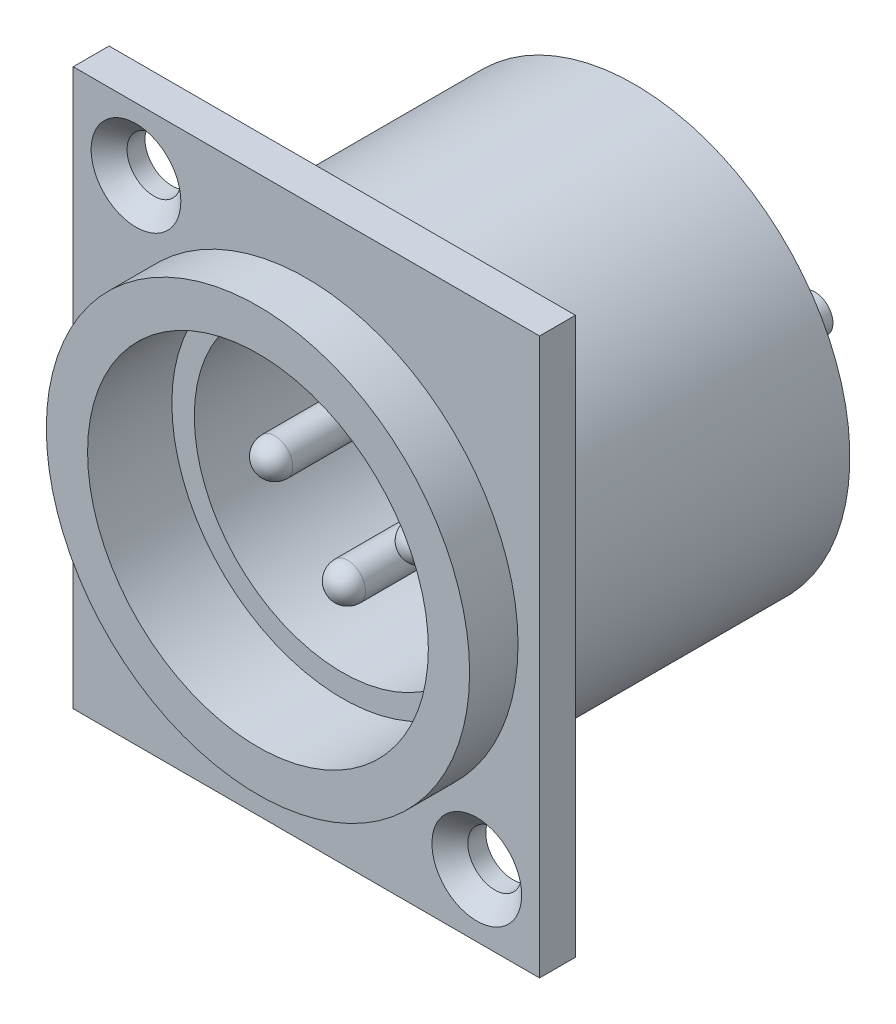
from build123d import *

# Parameters (mm, degrees)
ESQUISSE1_W             = 26
ESQUISSE1_H             = 31
ESQUISSE1_R             = 9.5
ESQUISSE1_R_2           = 1.5
BOSS_EXTRU_1_DEPTH      = 2
ESQUISSE2_R             = 11.8
ESQUISSE2_R_2           = 9.5
BOSS_EXTRU_2_DEPTH      = 2.7
CHANFREIN1_SIZE         = 1
ESQUISSE3_R             = 12
ESQUISSE3_R_2           = 8.25
BOSS_EXTRU_3_DEPTH      = 14.3
ESQUISSE4_R             = 12
BOSS_EXTRU_4_DEPTH      = 2
ESQUISSE5_R             = 1
BOSS_EXTRU_5_DEPTH      = 15
BOSS_EXTRU_5_DEPTH_BACK = 8
CONG_1_R                = 1


with BuildPart() as part:
    # Esquisse1 → Boss.-Extru.1 (new body)
    with BuildSketch(Plane.XY):
        with Locations((3.183515483, -7.666666667)):
            Rectangle(ESQUISSE1_W, ESQUISSE1_H)
        with Locations((3.183515483, -7.666666667)):
            Circle(ESQUISSE1_R, mode=Mode.SUBTRACT)
        with Locations((-6.316484517, 4.333333333)):
            Circle(ESQUISSE1_R_2, mode=Mode.SUBTRACT)
        with Locations((12.683515483, -19.666666667)):
            Circle(ESQUISSE1_R_2, mode=Mode.SUBTRACT)
    extrude(amount=BOSS_EXTRU_1_DEPTH)

    # Esquisse2 → Boss.-Extru.2 (add)
    with BuildSketch(Plane.XY.offset(2)):
        with Locations((3.183515483, -7.666666667)):
            Circle(ESQUISSE2_R)
        with Locations((3.183515483, -7.666666667)):
            Circle(ESQUISSE2_R_2, mode=Mode.SUBTRACT)
    extrude(amount=BOSS_EXTRU_2_DEPTH)

    # Chanfrein1
    chanfrein1_edges = [part.edges().sort_by_distance(p)[0] for p in [
        (-7.816484517, 4.333333333, 2),
        (11.183515483, -19.666666667, 2),
    ]]
    chamfer(chanfrein1_edges, length=CHANFREIN1_SIZE)

    # Esquisse3 → Boss.-Extru.3 (add)
    with BuildSketch(Plane(origin=(0, 0, 0), x_dir=(-1, 0, 0), z_dir=(0, 0, -1))):
        with Locations((-3.183515483, -7.666666667)):
            Circle(ESQUISSE3_R)
        with Locations((-3.183515483, -7.666666667)):
            Circle(ESQUISSE3_R_2, mode=Mode.SUBTRACT)
    extrude(amount=BOSS_EXTRU_3_DEPTH)

    # Esquisse4 → Boss.-Extru.4 (add)
    with BuildSketch(Plane(origin=(0, 0, -14.3), x_dir=(-1, 0, 0), z_dir=(0, 0, -1))):
        with Locations((-3.183515483, -7.666666667)):
            Circle(ESQUISSE4_R)
    extrude(amount=BOSS_EXTRU_4_DEPTH)

    # Esquisse5 → Boss.-Extru.5 (add, two sides)
    with BuildSketch(Plane.XY.offset(-14.3)) as boss_extru_5_sk:
        with Locations((7.243515483, -7.666666667)):
            Circle(ESQUISSE5_R)
        with Locations((-0.876484517, -7.666666667)):
            Circle(ESQUISSE5_R)
        with Locations((3.183515483, -11.646666667)):
            Circle(ESQUISSE5_R)
    extrude(amount=BOSS_EXTRU_5_DEPTH)
    extrude(boss_extru_5_sk.sketch, amount=-BOSS_EXTRU_5_DEPTH_BACK)

    # Congé1
    cong_1_edges = [part.edges().sort_by_distance(p)[0] for p in [
        (6.243515483, -7.666666667, 0.7),
        (-1.876484517, -7.666666667, 0.7),
        (2.183515483, -11.646666667, 0.7),
    ]]
    fillet(cong_1_edges, radius=CONG_1_R)


solid = part.part
